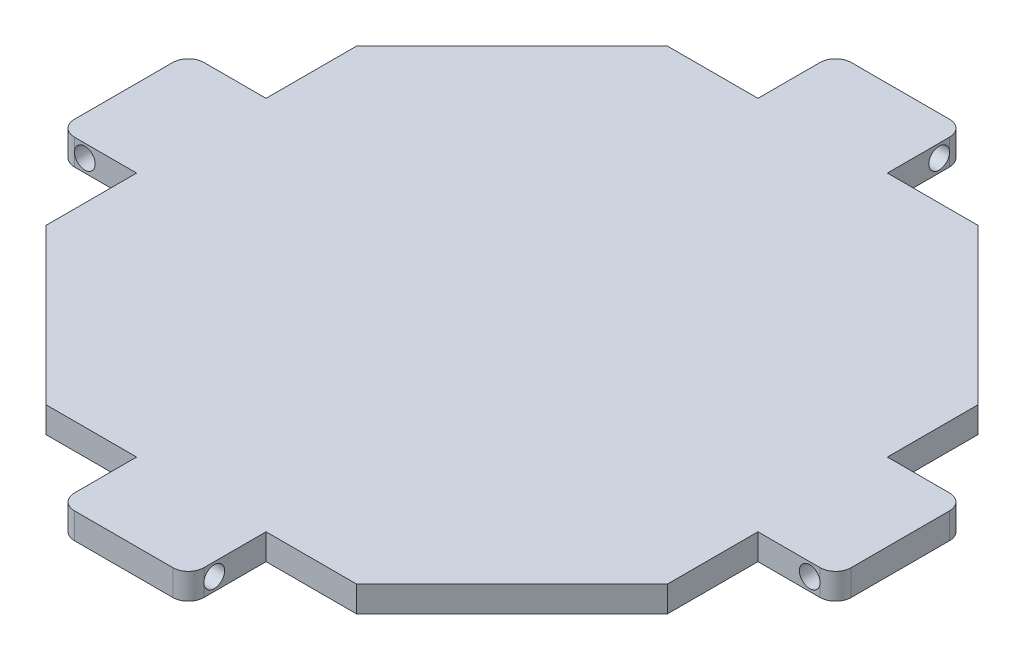
from build123d import *

# Parameters (mm, degrees)
EXTRUDE_1_DEPTH     = 5
FILLET_1_R          = 3
SKETCH_11_R         = 2
CUT_EXTRUDE_6_DEPTH = 88.5
SKETCH_12_R         = 2
CUT_EXTRUDE_7_DEPTH = 88.5


with BuildPart() as part:
    # 스케치1 → 보스-돌출1 (new body)
    with BuildSketch(Plane(origin=(0, 0, 0), x_dir=(1, 0, 0), z_dir=(0, 1, 0))):
        Polygon((-60, -30), (-30, -60), (-12.5, -60), (-12.5, -75), (12.5, -75), (12.5, -60), (30, -60), (60, -30), (60, -12.5), (75, -12.5), (75, 12.5), (60, 12.5), (60, 30), (30, 60), (12.5, 60), (12.5, 75), (-12.5, 75), (-12.5, 60), (-30, 60), (-60, 30), (-60, 12.5), (-75, 12.5), (-75, -12.5), (-60, -12.5), align=None)
    extrude(amount=EXTRUDE_1_DEPTH)

    # 필렛1
    fillet_1_edges = [part.edges().sort_by_distance(p)[0] for p in [
        (-12.5, 2.5, -75),
        (12.5, 2.5, -75),
        (75, 2.5, -12.5),
        (75, 2.5, 12.5),
        (12.5, 2.5, 75),
        (-12.5, 2.5, 75),
        (-75, 2.5, 12.5),
        (-75, 2.5, -12.5),
    ]]
    fillet(fillet_1_edges, radius=FILLET_1_R)

    # 스케치11 → 컷-돌출6 (cut, through all)
    with BuildSketch(Plane.XY.offset(12.5)):
        with Locations((-70, 2.5)):
            Circle(SKETCH_11_R)
        with Locations((70, 2.5)):
            Circle(SKETCH_11_R)
    extrude(amount=-CUT_EXTRUDE_6_DEPTH, mode=Mode.SUBTRACT)

    # 스케치12 → 컷-돌출7 (cut, through all)
    with BuildSketch(Plane.ZY.offset(12.5)):
        with Locations((-70, 2.5)):
            Circle(SKETCH_12_R)
        with Locations((70, 2.5)):
            Circle(SKETCH_12_R)
    extrude(amount=-CUT_EXTRUDE_7_DEPTH, mode=Mode.SUBTRACT)


solid = part.part
